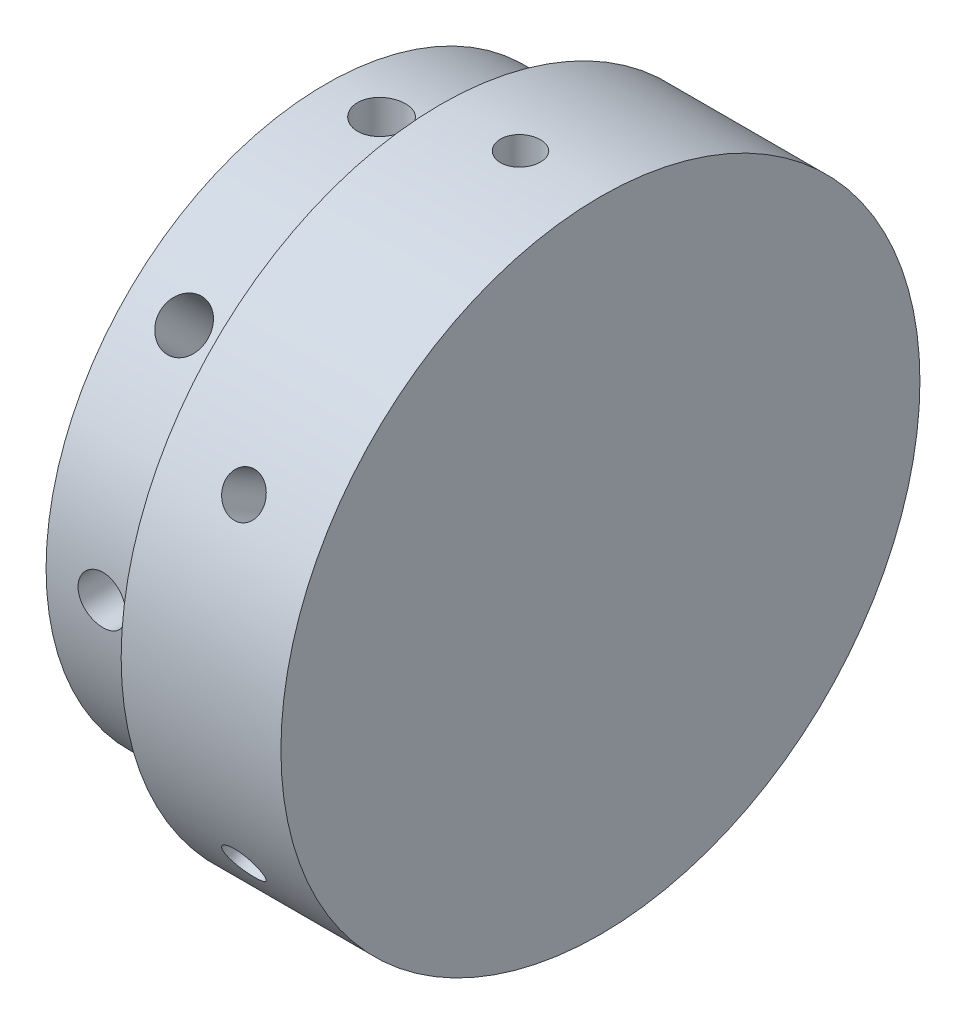
from build123d import *

# Parameters (mm, degrees)
SKETCH1_R           = 40
BOSS_EXTRUDE2_DEPTH = 10
SKETCH4_R           = 2.5
CUT_EXTRUDE3_DEPTH  = 15.4
CIRPATTERN1_COUNT   = 6
SKETCH3_R           = 35
BOSS_EXTRUDE4_DEPTH = 14.4
SKETCH8_R           = 3
CUT_EXTRUDE4_DEPTH  = 10
CIRPATTERN2_COUNT   = 8


with BuildPart() as part:
    # Sketch1 → Boss-Extrude2 (new body, symmetric)
    with BuildSketch(Plane(origin=(0, 0, 0), x_dir=(0, 0, -1), z_dir=(1, 0, 0))):
        Circle(SKETCH1_R)
    extrude(amount=BOSS_EXTRUDE2_DEPTH, both=True)

    # Sketch4 → Cut-Extrude3 (cut)
    with BuildSketch(Plane(origin=(0, 40, 0), x_dir=(1, 0, 0), z_dir=(0, 1, 0))):
        Circle(SKETCH4_R)
    cut_extrude3 = extrude(amount=-CUT_EXTRUDE3_DEPTH, mode=Mode.SUBTRACT)

    # CirPattern1: Cut-Extrude3 ×6 about axis
    cirpattern1_axis = Axis((0, 0, 0), (1, 0, 0))
    for i in range(1, CIRPATTERN1_COUNT):
        add(cut_extrude3.rotate(cirpattern1_axis, i * 360 / CIRPATTERN1_COUNT), mode=Mode.SUBTRACT)

    # Sketch3 → Boss-Extrude4 (add)
    with BuildSketch(Plane.ZY.offset(10)):
        Circle(SKETCH3_R)
    extrude(amount=BOSS_EXTRUDE4_DEPTH)

    # Sketch8 → Cut-Extrude4 (cut)
    with BuildSketch(Plane(origin=(0, 35, 0), x_dir=(1, 0, 0), z_dir=(0, 1, 0))):
        with Locations((-17.4, 0)):
            Circle(SKETCH8_R)
    cut_extrude4 = extrude(amount=-CUT_EXTRUDE4_DEPTH, mode=Mode.SUBTRACT)

    # CirPattern2: Cut-Extrude4 ×8 about axis
    cirpattern2_axis = Axis((0, 0, 0), (1, 0, 0))
    for i in range(1, CIRPATTERN2_COUNT):
        add(cut_extrude4.rotate(cirpattern2_axis, i * 360 / CIRPATTERN2_COUNT), mode=Mode.SUBTRACT)


solid = part.part
